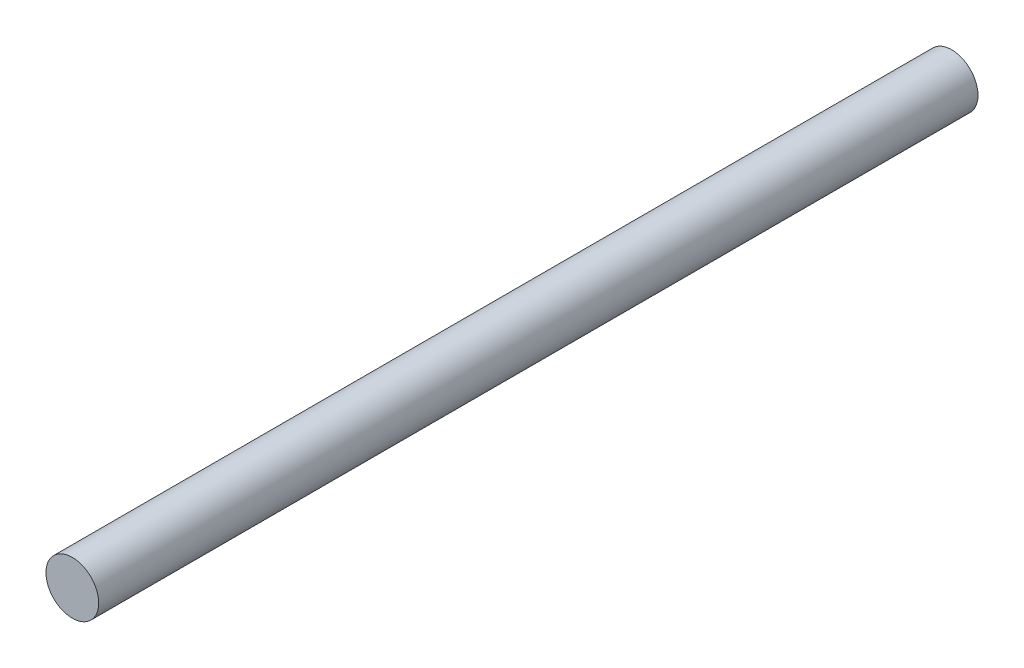
from build123d import *

# Parameters (mm, degrees)
SKETCH1_R           = 3
BOSS_EXTRUDE1_DEPTH = 100


with BuildPart() as part:
    # Sketch1 → Boss-Extrude1 (new body)
    with BuildSketch(Plane.XY):
        with Locations((-327.499977221, 138.064705284)):
            Circle(SKETCH1_R)
    extrude(amount=BOSS_EXTRUDE1_DEPTH)


solid = part.part
